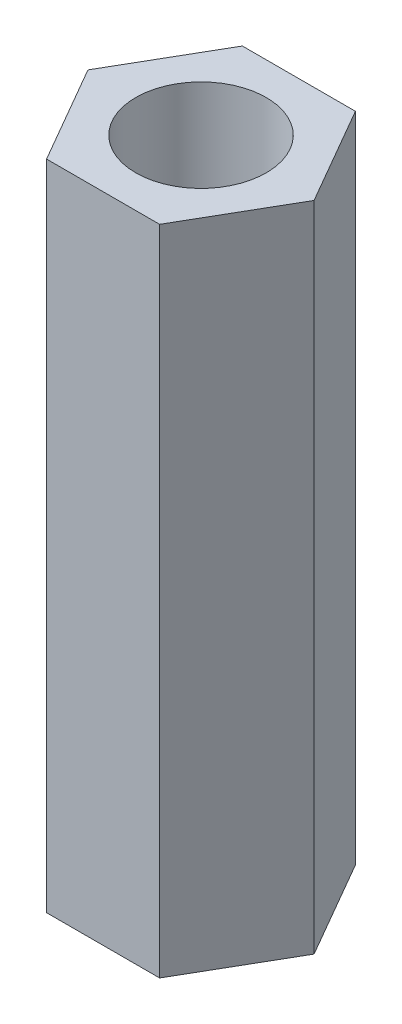
from build123d import *

# Parameters (mm, degrees)
SKETCH1_R           = 2
BOSS_EXTRUDE1_DEPTH = 20


with BuildPart() as part:
    # Sketch1 → Boss-Extrude1 (new body)
    with BuildSketch(Plane(origin=(0, 0, 0), x_dir=(1, 0, 0), z_dir=(0, 1, 0))):
        Polygon((1.732050808, -3), (3.464101615, 0), (1.732050808, 3), (-1.732050808, 3), (-3.464101615, 0), (-1.732050808, -3), align=None)
        Circle(SKETCH1_R, mode=Mode.SUBTRACT)
    extrude(amount=BOSS_EXTRUDE1_DEPTH)


solid = part.part
